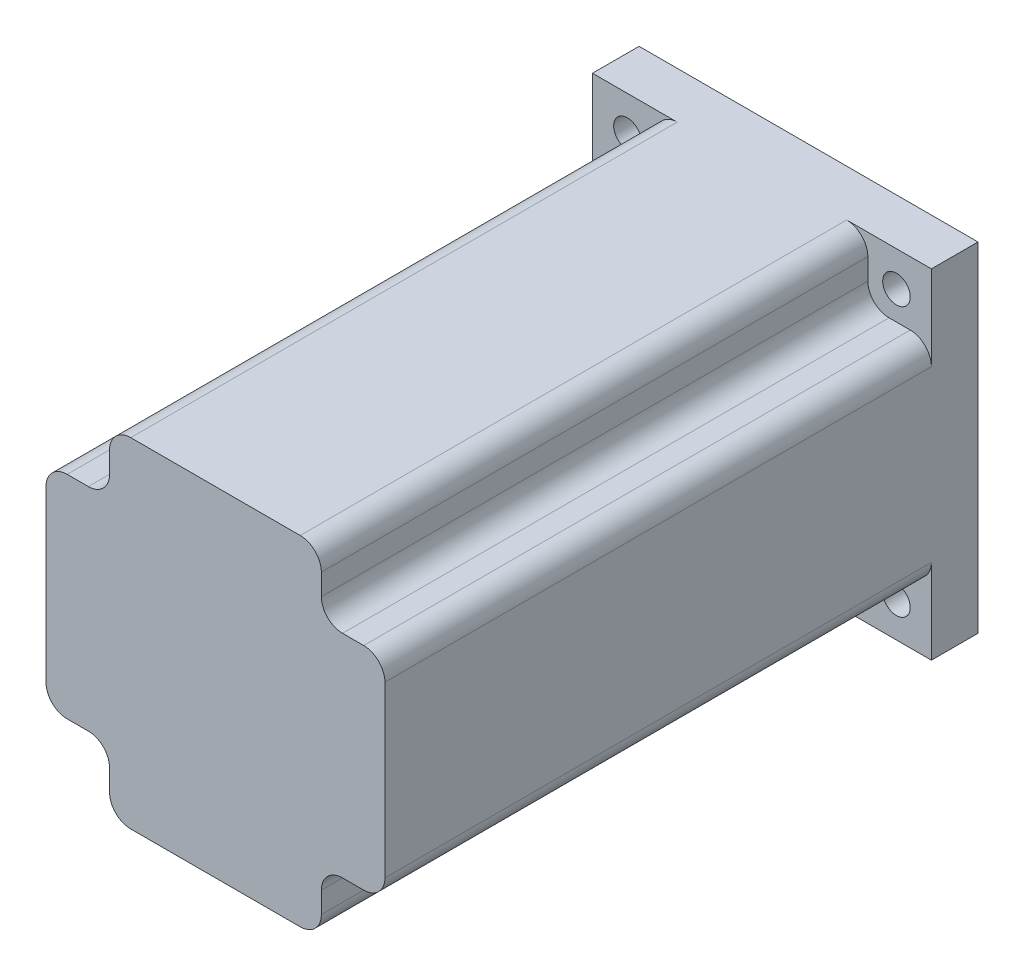
from build123d import *

# Parameters (mm, degrees)
SKETCH_1_W              = 80
SKETCH_1_H              = 80
EXTRUDE_1_DEPTH         = 140
SKETCH_2_OUTSIDE_W      = 118
SKETCH_2_OUTSIDE_H      = 118
CUT_EXTRUDE_1_DEPTH     = 129
HOLE_WIZARD_6_5_6_5_1_D = 6.5


with BuildPart() as part:
    # 草图1 → 凸台-拉伸1 (new body)
    with BuildSketch(Plane.XY):
        Rectangle(SKETCH_1_W, SKETCH_1_H)
    extrude(amount=EXTRUDE_1_DEPTH)

    # 草图2 outside → 切除-拉伸1 (cut)
    with BuildSketch(Plane.XY.offset(140)):
        Rectangle(SKETCH_2_OUTSIDE_W, SKETCH_2_OUTSIDE_H)
        with BuildLine():
            Line((30, 25), (35, 25))
            ThreePointArc((35, 25), (38.535533906, 23.535533906), (40, 20))
            Line((40, 20), (40, -20))
            ThreePointArc((40, -20), (38.535533906, -23.535533906), (35, -25))
            Line((35, -25), (30, -25))
            ThreePointArc((30, -25), (26.464466094, -26.464466094), (25, -30))
            Line((25, -30), (25, -35))
            ThreePointArc((25, -35), (23.535533906, -38.535533906), (20, -40))
            Line((20, -40), (-20, -40))
            ThreePointArc((-20, -40), (-23.535533906, -38.535533906), (-25, -35))
            Line((-25, -35), (-25, -30))
            ThreePointArc((-25, -30), (-26.464466094, -26.464466094), (-30, -25))
            Line((-30, -25), (-35, -25))
            ThreePointArc((-35, -25), (-38.535533906, -23.535533906), (-40, -20))
            Line((-40, -20), (-40, 20))
            ThreePointArc((-40, 20), (-38.535533906, 23.535533906), (-35, 25))
            Line((-35, 25), (-30, 25))
            ThreePointArc((-30, 25), (-26.464466094, 26.464466094), (-25, 30))
            Line((-25, 30), (-25, 35))
            ThreePointArc((-25, 35), (-23.535533906, 38.535533906), (-20, 40))
            Line((-20, 40), (20, 40))
            ThreePointArc((20, 40), (23.535533906, 38.535533906), (25, 35))
            Line((25, 35), (25, 30))
            ThreePointArc((25, 30), (26.464466094, 26.464466094), (30, 25))
        make_face(mode=Mode.SUBTRACT)
    extrude(amount=-CUT_EXTRUDE_1_DEPTH, mode=Mode.SUBTRACT)

    # Ø6.5 (6.5) 直径孔1 (through all)
    with Locations(Plane(origin=(-31.75, 31.75, 11), x_dir=(1, 0, 0), z_dir=(0, 0, 1))):
        with Locations((0, 0), (63.5, 0), (63.5, -63.5), (0, -63.5)):
            Hole(HOLE_WIZARD_6_5_6_5_1_D / 2)


solid = part.part
